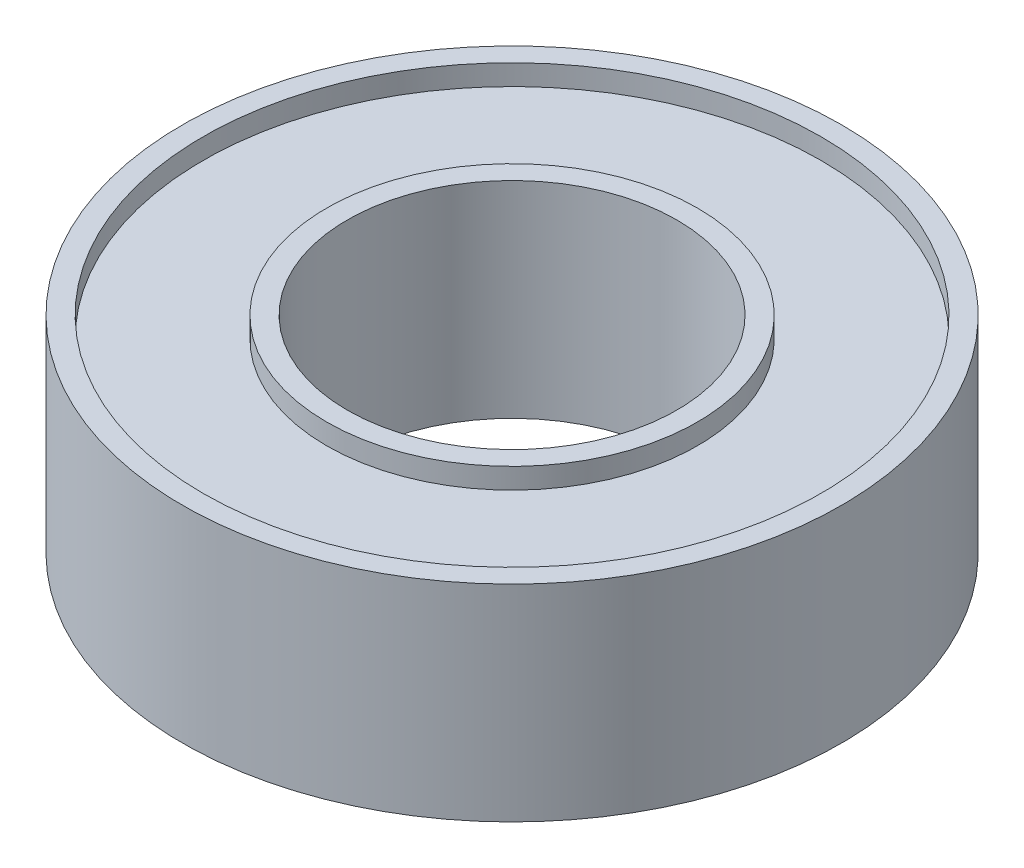
from build123d import *


with BuildPart() as part:
    # Sketch1 → Revolve1 (revolve)
    with BuildSketch(Plane.XY):
        Polygon((-4, 4.5), (-4.5, 4.5), (-4.5, 4), (-7.5, 4), (-7.5, 4.5), (-8, 4.5), (-8, -0.5), (-7.5, -0.5), (-7.5, 0), (-4.5, 0), (-4.5, -0.5), (-4, -0.5), align=None)
    revolve(axis=Axis((0, 0, 0), (0, 1, 0)))


solid = part.part
